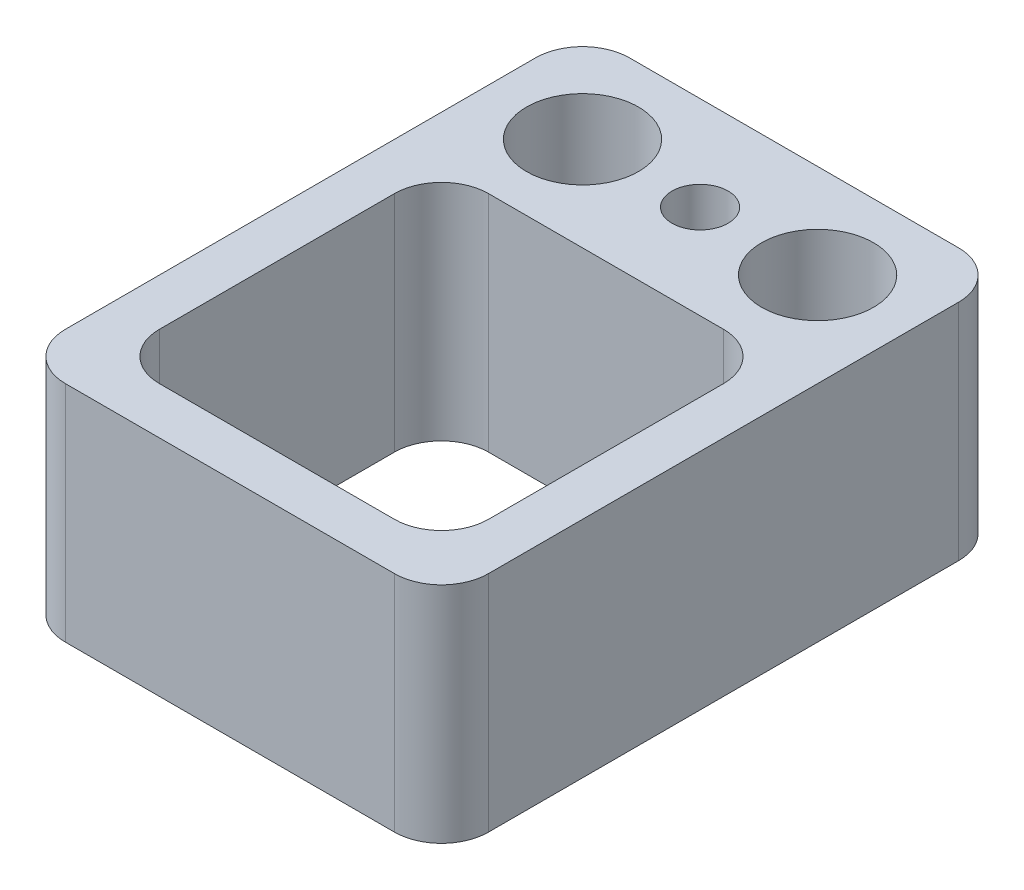
from build123d import *

# Parameters (mm, degrees)
SKETCH1_W                           = 9
SKETCH1_H                           = 12
EXTRUDE1_DEPTH                      = 4.7625
SKETCH2_W                           = 7
SKETCH2_H                           = 7
EXTRUDE2_DEPTH                      = 5.7625
F_0_80_TAPPED_HOLE1_D               = 1.19126
F_3_32_0_09375_DIAMETER_HOLE1_D     = 2.38125
F_3_32_0_09375_DIAMETER_HOLE1_DEPTH = 10
F_3_32_0_09375_DIAMETER_HOLE1_TIP   = 0.715399675
FILLET7_R                           = 1


with BuildPart() as part:
    # Sketch1 → Extrude1 (new body)
    with BuildSketch(Plane(origin=(0, 0, 0), x_dir=(1, 0, 0), z_dir=(0, 1, 0))):
        Rectangle(SKETCH1_W, SKETCH1_H)
    extrude(amount=EXTRUDE1_DEPTH)

    # Sketch2 → Extrude2 (cut, through all)
    with BuildSketch(Plane(origin=(0, 4.7625, 0), x_dir=(1, 0, 0), z_dir=(0, 1, 0))):
        with Locations((0, -1.5)):
            Rectangle(SKETCH2_W, SKETCH2_H)
    extrude(amount=-EXTRUDE2_DEPTH, mode=Mode.SUBTRACT)

    # #0-80 Tapped Hole1 (through all)
    with Locations(Plane(origin=(0, 4.7625, -4), x_dir=(0, 0, 1), z_dir=(0, 1, 0))):
        with Locations((0, 0)):
            Hole(F_0_80_TAPPED_HOLE1_D / 2)

    # 3/32 (0.09375) Diameter Hole1
    with Locations(Plane(origin=(-2.5, 4.7625, -4), x_dir=(0, 0, 1), z_dir=(0, 1, 0))):
        with Locations((0, 0), (0, 5)):
            Hole(F_3_32_0_09375_DIAMETER_HOLE1_D / 2, depth=F_3_32_0_09375_DIAMETER_HOLE1_DEPTH)
            with Locations((0, 0, -(F_3_32_0_09375_DIAMETER_HOLE1_DEPTH + F_3_32_0_09375_DIAMETER_HOLE1_TIP / 2))):  # 118° drill point
                Cone(0, F_3_32_0_09375_DIAMETER_HOLE1_D / 2, F_3_32_0_09375_DIAMETER_HOLE1_TIP, mode=Mode.SUBTRACT)

    # Fillet7
    fillet7_edges = [part.edges().sort_by_distance(p)[0] for p in [
        (-3.5, 2.38125, 5),
        (-3.5, 2.38125, -2),
        (3.5, 2.38125, -2),
        (3.5, 2.38125, 5),
        (-4.5, 2.38125, -6),
        (4.5, 2.38125, -6),
        (4.5, 2.38125, 6),
        (-4.5, 2.38125, 6),
    ]]
    fillet(fillet7_edges, radius=FILLET7_R)


solid = part.part
